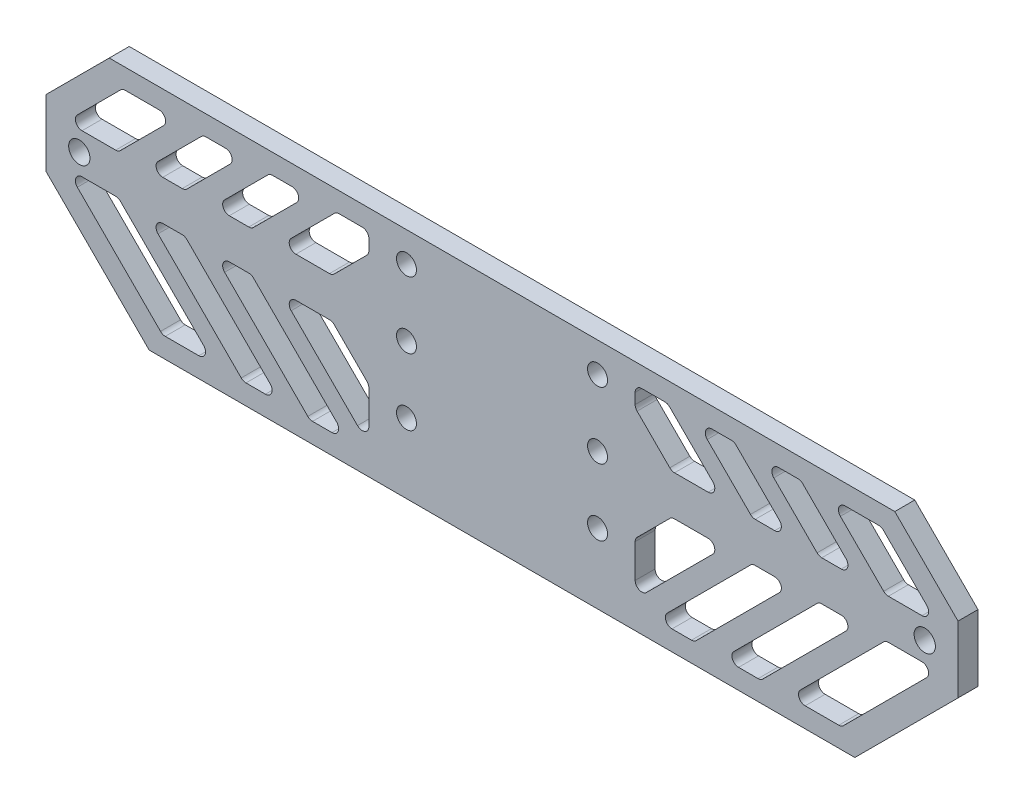
from build123d import *

# Parameters (mm, degrees)
SKETCH_1_W             = 32.7
SKETCH_1_H             = 29
SKETCH_1_R             = 1.5
EXTRUDE_1_DEPTH        = 3
CHAMFER_1_SIZE         = 3
EXTRUDE_2_DEPTH        = 3
CHAMFER_2_SIZE         = 9.5
EXTRUDE_3_DEPTH        = 3
SKETCH_6_R             = 1.6
CUT_EXTRUDE_2_DEPTH    = 4
CUT_EXTRUDE_4_DEPTH    = 10
FILLET_2_R             = 1
FILLET_2_OF_MIRROR_1_R = 1


with BuildPart() as part:
    # 草图1 → 凸台-拉伸1 (new body)
    with BuildSketch(Plane.XY):
        Rectangle(SKETCH_1_W, SKETCH_1_H)
        with Locations((-14.35, -10)):
            Circle(SKETCH_1_R, mode=Mode.SUBTRACT)
        with Locations((-14.35, 10)):
            Circle(SKETCH_1_R, mode=Mode.SUBTRACT)
        with Locations((14.35, 10)):
            Circle(SKETCH_1_R, mode=Mode.SUBTRACT)
        with Locations((14.35, -10)):
            Circle(SKETCH_1_R, mode=Mode.SUBTRACT)
        with Locations((-14.35, 0)):
            Circle(SKETCH_1_R, mode=Mode.SUBTRACT)
        with Locations((14.35, 0)):
            Circle(SKETCH_1_R, mode=Mode.SUBTRACT)
    extrude(amount=EXTRUDE_1_DEPTH)

    # 倒角1
    chamfer_1_edges = [part.edges().sort_by_distance(p)[0] for p in [
        (16.35, -14.5, 1.5),
        (-16.35, -14.5, 1.5),
        (-16.35, 14.5, 1.5),
        (16.35, 14.5, 1.5),
    ]]
    chamfer(chamfer_1_edges, length=CHAMFER_1_SIZE)

    # 草图3 → 凸台-拉伸2 (add)
    with BuildSketch(Plane.XY.offset(3)):
        Polygon((-13.35, 14.5), (-68.5, 14.5), (-68.5, -14.5), (-13.35, -14.5), (-16.35, -11.5), (-16.35, 11.5), align=None)
        Polygon((68.5, 14.5), (13.35, 14.5), (16.35, 11.5), (16.35, -11.5), (13.35, -14.5), (68.5, -14.5), align=None)
    extrude(amount=-EXTRUDE_2_DEPTH)

    # 倒角2
    chamfer_2_edges = [part.edges().sort_by_distance(p)[0] for p in [
        (-68.5, -14.5, 1.5),
        (-68.5, 14.5, 1.5),
        (68.5, -14.5, 1.5),
        (68.5, 14.5, 1.5),
    ]]
    chamfer(chamfer_2_edges, length=CHAMFER_2_SIZE)

    # 草图4 → 凸台-拉伸3 (add)
    with BuildSketch(Plane(origin=(0, 0, 0), x_dir=(-1, 0, 0), z_dir=(0, 0, -1))):
        Polygon((-59, -14.5), (-53, -20.5), (53, -20.5), (59, -14.5), align=None)
    extrude(amount=-EXTRUDE_3_DEPTH)

    # 草图6 → 切除-拉伸2 (cut, through all)
    with BuildSketch(Plane(origin=(0, 0, 0), x_dir=(-1, 0, 0), z_dir=(0, 0, -1))):
        with Locations((-63.5, 0)):
            Circle(SKETCH_6_R)
    cut_extrude_2 = extrude(amount=-CUT_EXTRUDE_2_DEPTH, mode=Mode.SUBTRACT)

    # 草图7 → 切除-拉伸4 (cut)
    with BuildSketch(Plane(origin=(0, 0, 0), x_dir=(-1, 0, 0), z_dir=(0, 0, -1))):
        Polygon((-57, 11.5), (-65.5, 3), (-57.621320344, 3), (-49.121320344, 11.5), align=None)
        Polygon((-57.621320344, -3), (-65.5, -3), (-51, -17.5), (-43.121320344, -17.5), align=None)
        Polygon((-47.621320344, -3), (-53.378679656, -3), (-38.878679656, -17.5), (-33.121320344, -17.5), align=None)
        Polygon((-44.878679656, 11.5), (-53.378679656, 3), (-47.621320344, 3), (-39.121320344, 11.5), align=None)
        Polygon((-34.878679656, 11.5), (-43.378679656, 3), (-37.621320344, 3), (-29.121320344, 11.5), align=None)
        Polygon((-23.121320344, -17.5), (-37.621320344, -3), (-43.378679656, -3), (-28.878679656, -17.5), align=None)
        Polygon((-20, -8.5), (-25.5, -3), (-33.378679656, -3), (-20, -16.378679656), align=None)
        Polygon((-33.378679656, 3), (-25.5, 3), (-20, 8.5), (-20, 11.5), (-23, 11.5), (-24.878679656, 11.5), align=None)
    cut_extrude_4 = extrude(amount=-CUT_EXTRUDE_4_DEPTH, mode=Mode.SUBTRACT)

    # 圆角2
    fillet_2_edges = [part.edges().sort_by_distance(p)[0] for p in [
        (53.378679656, -3, 1.5),
        (47.621320344, -3, 1.5),
        (33.121320344, -17.5, 1.5),
        (38.878679656, -17.5, 1.5),
        (57.621320344, -3, 1.5),
        (43.121320344, -17.5, 1.5),
        (51, -17.5, 1.5),
        (65.5, -3, 1.5),
        (37.621320344, 3, 1.5),
        (43.378679656, 3, 1.5),
        (34.878679656, 11.5, 1.5),
        (29.121320344, 11.5, 1.5),
        (47.621320344, 3, 1.5),
        (53.378679656, 3, 1.5),
        (44.878679656, 11.5, 1.5),
        (39.121320344, 11.5, 1.5),
        (33.378679656, -3, 1.5),
        (25.5, -3, 1.5),
        (20, -8.5, 1.5),
        (20, -16.378679656, 1.5),
        (43.378679656, -3, 1.5),
        (37.621320344, -3, 1.5),
        (23.121320344, -17.5, 1.5),
        (28.878679656, -17.5, 1.5),
        (33.378679656, 3, 1.5),
        (24.878679656, 11.5, 1.5),
        (20, 11.5, 1.5),
        (20, 8.5, 1.5),
        (25.5, 3, 1.5),
        (57.621320344, 3, 1.5),
        (65.5, 3, 1.5),
        (57, 11.5, 1.5),
        (49.121320344, 11.5, 1.5),
    ]]
    fillet(fillet_2_edges, radius=FILLET_2_R)

    # 镜向1: 切除-拉伸2, 切除-拉伸4 across plane
    add(cut_extrude_2.mirror(Plane(origin=(0, 0, 0), x_dir=(0, 0, 1), z_dir=(1, 0, 0))), mode=Mode.SUBTRACT)
    add(cut_extrude_4.mirror(Plane(origin=(0, 0, 0), x_dir=(0, 0, 1), z_dir=(1, 0, 0))), mode=Mode.SUBTRACT)

    # 圆角2 of 镜向1
    fillet_2_of_mirror_1_edges = [part.edges().sort_by_distance(p)[0] for p in [
        (-53.378679656, -3, 1.5),
        (-47.621320344, -3, 1.5),
        (-33.121320344, -17.5, 1.5),
        (-38.878679656, -17.5, 1.5),
        (-57.621320344, -3, 1.5),
        (-43.121320344, -17.5, 1.5),
        (-51, -17.5, 1.5),
        (-65.5, -3, 1.5),
        (-37.621320344, 3, 1.5),
        (-43.378679656, 3, 1.5),
        (-34.878679656, 11.5, 1.5),
        (-29.121320344, 11.5, 1.5),
        (-47.621320344, 3, 1.5),
        (-53.378679656, 3, 1.5),
        (-44.878679656, 11.5, 1.5),
        (-39.121320344, 11.5, 1.5),
        (-33.378679656, -3, 1.5),
        (-25.5, -3, 1.5),
        (-20, -8.5, 1.5),
        (-20, -16.378679656, 1.5),
        (-43.378679656, -3, 1.5),
        (-37.621320344, -3, 1.5),
        (-23.121320344, -17.5, 1.5),
        (-28.878679656, -17.5, 1.5),
        (-33.378679656, 3, 1.5),
        (-24.878679656, 11.5, 1.5),
        (-20, 11.5, 1.5),
        (-20, 8.5, 1.5),
        (-25.5, 3, 1.5),
        (-57.621320344, 3, 1.5),
        (-65.5, 3, 1.5),
        (-57, 11.5, 1.5),
        (-49.121320344, 11.5, 1.5),
    ]]
    fillet(fillet_2_of_mirror_1_edges, radius=FILLET_2_OF_MIRROR_1_R)


solid = part.part
